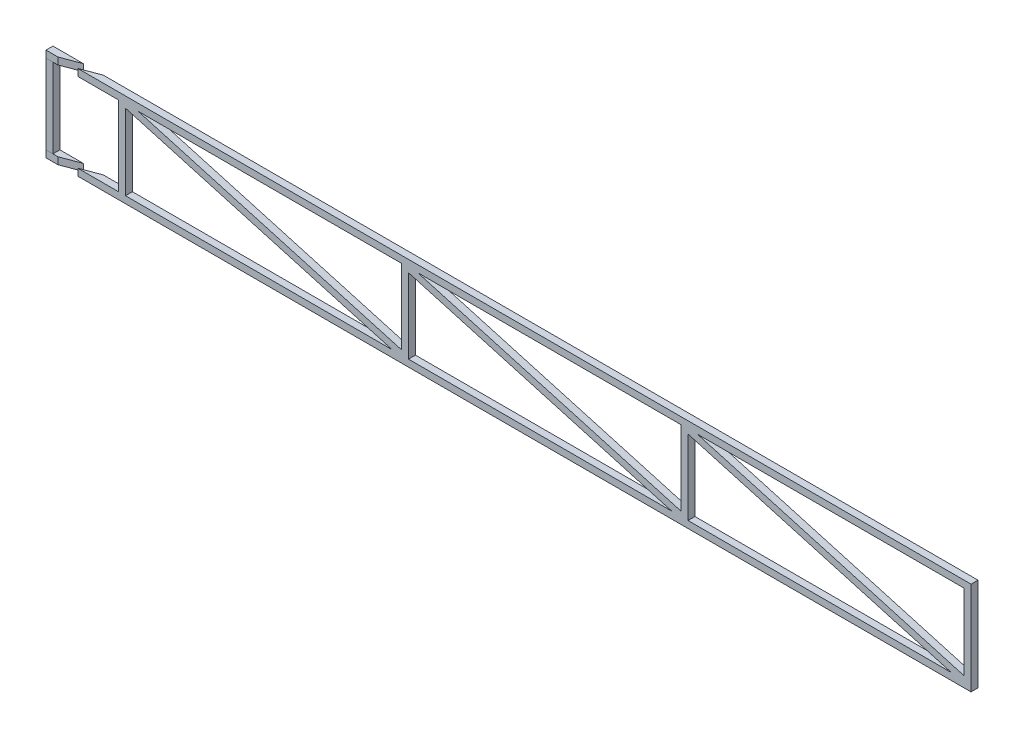
from build123d import *

# Parameters (mm, degrees)
BOSS_EXTRUDE1_DEPTH   = 3.175
BOSS_EXTRUDE1_2_DEPTH = 3.175
SKETCH2_W             = 3.175
SKETCH2_H             = 36.35
BOSS_EXTRUDE2_DEPTH   = 3.175
SKETCH3_W             = 3.175
SKETCH3_H             = 3.175
BOSS_EXTRUDE8_DEPTH   = 423.175
BOSS_EXTRUDE8_2_DEPTH = 423.175
SKETCH4_W             = 3.175
SKETCH4_H             = 36.35
CUT_EXTRUDE1_DEPTH    = 427.326430831
CUT_EXTRUDE7_DEPTH    = 3.175
CUT_EXTRUDE8_DEPTH    = 3.175
SKETCH11_W            = 386.825
SKETCH11_H            = 36.35
BOSS_EXTRUDE9_DEPTH   = 3.175
CUT_EXTRUDE9_DEPTH    = 3.175


with BuildPart() as part:
    # Sketch1 → Boss-Extrude1 (new body)
    with BuildSketch(Plane.XY):
        Polygon((15, 45), (405, 45), (405, 48.175), (18.175, 48.175), (-18.175, 48.175), (-18.175, 45), (-15, 45), align=None)
    extrude(amount=BOSS_EXTRUDE1_DEPTH)



with BuildPart() as body_2:
    # Sketch1 → Boss-Extrude1 2 (new body)
    with BuildSketch(Plane.XY):
        Polygon((-18.175, 15), (-15, 15), (15, 15), (405, 15), (405, 11.825), (18.175, 11.825), (-18.175, 11.825), align=None)
    extrude(amount=BOSS_EXTRUDE1_2_DEPTH)


with BuildPart() as part_1:
    add(part.part)

    add(body_2.part)  # Boss-Extrude2 merges body 2
    # Sketch2 → Boss-Extrude2 (add)
    with BuildSketch(Plane.XY.offset(3.175)):
        with Locations((-16.5875, 30)):
            Rectangle(SKETCH2_W, SKETCH2_H)
        Polygon((15, 11.825), (22.589723325, 11.825), (112.5, 46.473699254), (112.5, 12.285600704), (112.5, 11.825), (120.025102002, 11.825), (208.4125, 46.469905429), (208.4125, 11.825), (215.937602002, 11.825), (304.325, 46.469905429), (304.325, 11.825), (311.914723325, 11.825), (401.825, 46.473699254), (401.825, 11.825), (405, 11.825), (405, 48.175), (397.410276675, 48.175), (307.5, 13.526300746), (307.5, 48.175), (299.974897998, 48.175), (211.5875, 13.530094571), (211.5875, 48.175), (204.062397998, 48.175), (115.675, 13.530094571), (115.675, 48.175), (108.085276675, 48.175), (18.175, 13.526300746), (18.175, 48.175), (15, 48.175), align=None)
    extrude(amount=BOSS_EXTRUDE2_DEPTH)

    # Sketch4 → Cut-Extrude1 (cut, through all)
    with BuildSketch(Plane(origin=(405, 0, 0), x_dir=(0, 0, -1), z_dir=(1, 0, 0))):
        with Locations((-1.5875, 30)):
            Rectangle(SKETCH4_W, SKETCH4_H)
    extrude(amount=-CUT_EXTRUDE1_DEPTH, mode=Mode.SUBTRACT)


with BuildPart() as body_2_2:
    # Sketch3 → Boss-Extrude8 (new body)
    with BuildSketch(Plane(origin=(405, 0, 0), x_dir=(0, 0, -1), z_dir=(1, 0, 0))):
        with Locations((-4.7625, 49.7625)):
            Rectangle(SKETCH3_W, SKETCH3_H)
    extrude(amount=-BOSS_EXTRUDE8_DEPTH)

    # Sketch9 → Cut-Extrude8 (cut)
    with BuildSketch(Plane(origin=(0, 51.35, 0), x_dir=(1, 0, 0), z_dir=(0, 1, 0))):
        Polygon((-3.638332101, -6.35), (4.861361865, -3.175), (-4.211973934, -3.175), (-12.711667899, -6.35), align=None)
    extrude(amount=-CUT_EXTRUDE8_DEPTH, mode=Mode.SUBTRACT)


with BuildPart() as body_3:
    # Sketch3 → Boss-Extrude8 2 (new body)
    with BuildSketch(Plane(origin=(405, 0, 0), x_dir=(0, 0, -1), z_dir=(1, 0, 0))):
        with Locations((-4.7625, 10.2375)):
            Rectangle(SKETCH3_W, SKETCH3_H)
    extrude(amount=-BOSS_EXTRUDE8_2_DEPTH)

    # Sketch5 → Cut-Extrude7 (cut)
    with BuildSketch(Plane.XZ.offset(-8.65)):
        Polygon((-4.211973934, 3.175), (4.861361865, 3.175), (-3.638332101, 6.35), (-12.711667899, 6.35), align=None)
    extrude(amount=-CUT_EXTRUDE7_DEPTH, mode=Mode.SUBTRACT)


with BuildPart() as cut_extrude1_piece_1:
    # of the separate pieces the step leaves, piece 1, a body of its own (cut_extrude1_pieces)
    add(part_1.part.solids().sort_by_distance((401.825, 11.825, 3.175))[0])



with BuildPart() as cut_extrude1_piece_2:
    # of the separate pieces the step leaves, piece 2, a body of its own (cut_extrude1_pieces)
    add(part_1.part.solids().sort_by_distance((-15, 48.175, 3.175))[0])


with BuildPart() as cut_extrude7_piece_1:
    # of the separate pieces the step leaves, piece 1, a body of its own (cut_extrude7_pieces)
    add(body_3.part.solids().sort_by_distance((405, 11.825, 3.175))[0])


with BuildPart() as cut_extrude7_piece_2:
    # of the separate pieces the step leaves, piece 2, a body of its own (cut_extrude7_pieces)
    add(body_3.part.solids().sort_by_distance((-12.711667899, 11.825, 6.35))[0])


with BuildPart() as cut_extrude8_piece_1:
    # of the separate pieces the step leaves, piece 1, a body of its own (cut_extrude8_pieces)
    add(body_2_2.part.solids().sort_by_distance((405, 51.35, 6.35))[0])


with BuildPart() as cut_extrude8_piece_2:
    # of the separate pieces the step leaves, piece 2, a body of its own (cut_extrude8_pieces)
    add(body_2_2.part.solids().sort_by_distance((-12.711667899, 51.35, 6.35))[0])


with BuildPart() as cut_extrude1_piece_1_1:
    add(cut_extrude1_piece_1.part)

    add(cut_extrude7_piece_1.part)  # Boss-Extrude9 merges Cut-Extrude7 piece 1

    add(cut_extrude8_piece_1.part)  # Boss-Extrude9 merges Cut-Extrude8 piece 1
    # Sketch11 → Boss-Extrude9 (add)
    with BuildSketch(Plane(origin=(0, 0, 3.175), x_dir=(-1, 0, 0), z_dir=(0, 0, -1))):
        with Locations((-211.5875, 30)):
            Rectangle(SKETCH11_W, SKETCH11_H)
    extrude(amount=-BOSS_EXTRUDE9_DEPTH)

    # Sketch12 → Cut-Extrude9 (cut)
    with BuildSketch(Plane(origin=(0, 0, 3.175), x_dir=(-1, 0, 0), z_dir=(0, 0, -1))):
        Polygon((-18.175, 46.52461662), (-140.253692473, 11.825), (-18.175, 11.825), align=None)
        Polygon((-23.981307527, 48.175), (-144.4725, 48.175), (-144.4725, 13.926613978), align=None)
        Polygon((-268.138692473, 11.825), (-147.6475, 11.825), (-147.6475, 46.073386022), align=None)
        Polygon((-272.3575, 13.926613978), (-151.866307527, 48.175), (-272.3575, 48.175), align=None)
        Polygon((-396.023692473, 11.825), (-275.5325, 11.825), (-275.5325, 46.073386022), align=None)
        Polygon((-401.83, 13.47538338), (-279.751307527, 48.175), (-401.83, 48.175), align=None)
    extrude(amount=-CUT_EXTRUDE9_DEPTH, mode=Mode.SUBTRACT)


solid = Compound([cut_extrude1_piece_2.part, cut_extrude7_piece_2.part, cut_extrude8_piece_2.part, cut_extrude1_piece_1_1.part])
